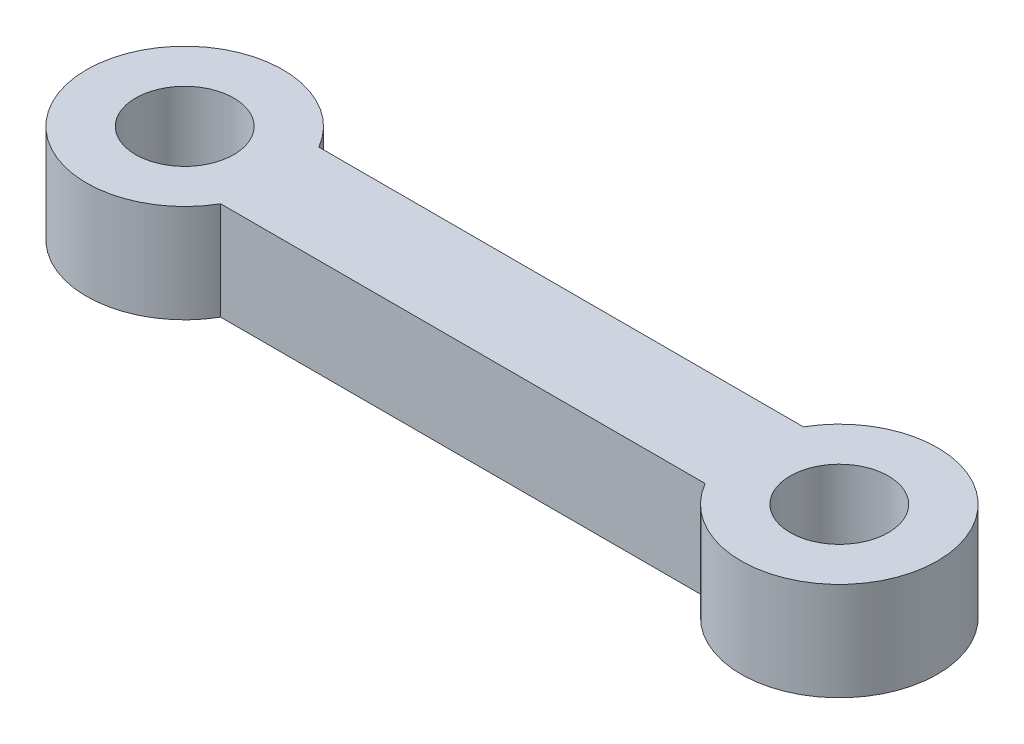
from build123d import *

# Parameters (mm, degrees)
SKETCH1_R           = 1.5
BOSS_EXTRUDE1_DEPTH = 3


with BuildPart() as part:
    # Sketch1 → Boss-Extrude1 (new body)
    with BuildSketch(Plane(origin=(0, 0, 0), x_dir=(1, 0, 0), z_dir=(0, 1, 0))):
        with BuildLine():
            Line((2.598076211, 1.5), (17.401923789, 1.5))
            ThreePointArc((17.401923789, 1.5), (23, 0), (17.401923789, -1.5))
            Line((17.401923789, -1.5), (2.598076211, -1.5))
            ThreePointArc((2.598076211, -1.5), (-3, 0), (2.598076211, 1.5))
        make_face()
        Circle(SKETCH1_R, mode=Mode.SUBTRACT)
        with Locations((20, 0)):
            Circle(SKETCH1_R, mode=Mode.SUBTRACT)
    extrude(amount=BOSS_EXTRUDE1_DEPTH)


solid = part.part
